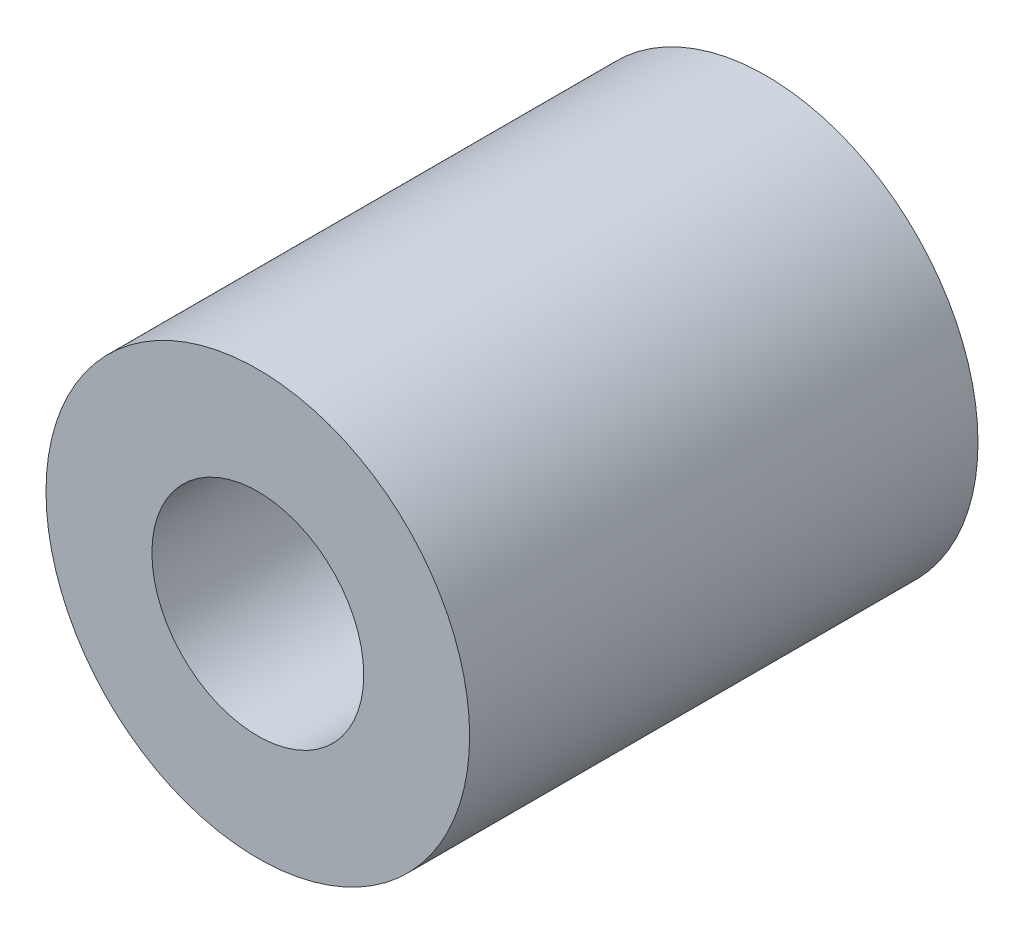
from build123d import *

# Parameters (mm, degrees)
SKETCH1_R                 = 5
BOSS_EXTRUDE1_DEPTH       = 12
F_5_0MM_DOWEL_HOLE1_D     = 5
F_5_0MM_DOWEL_HOLE1_DEPTH = 12


with BuildPart() as part:
    # Sketch1 → Boss-Extrude1 (new body)
    with BuildSketch(Plane.XY):
        Circle(SKETCH1_R)
    extrude(amount=BOSS_EXTRUDE1_DEPTH)

    # Ø5.0mm Dowel Hole1
    with Locations(Plane.XY.offset(12)):
        with Locations((0, 0)):
            Hole(F_5_0MM_DOWEL_HOLE1_D / 2, depth=F_5_0MM_DOWEL_HOLE1_DEPTH)


solid = part.part
